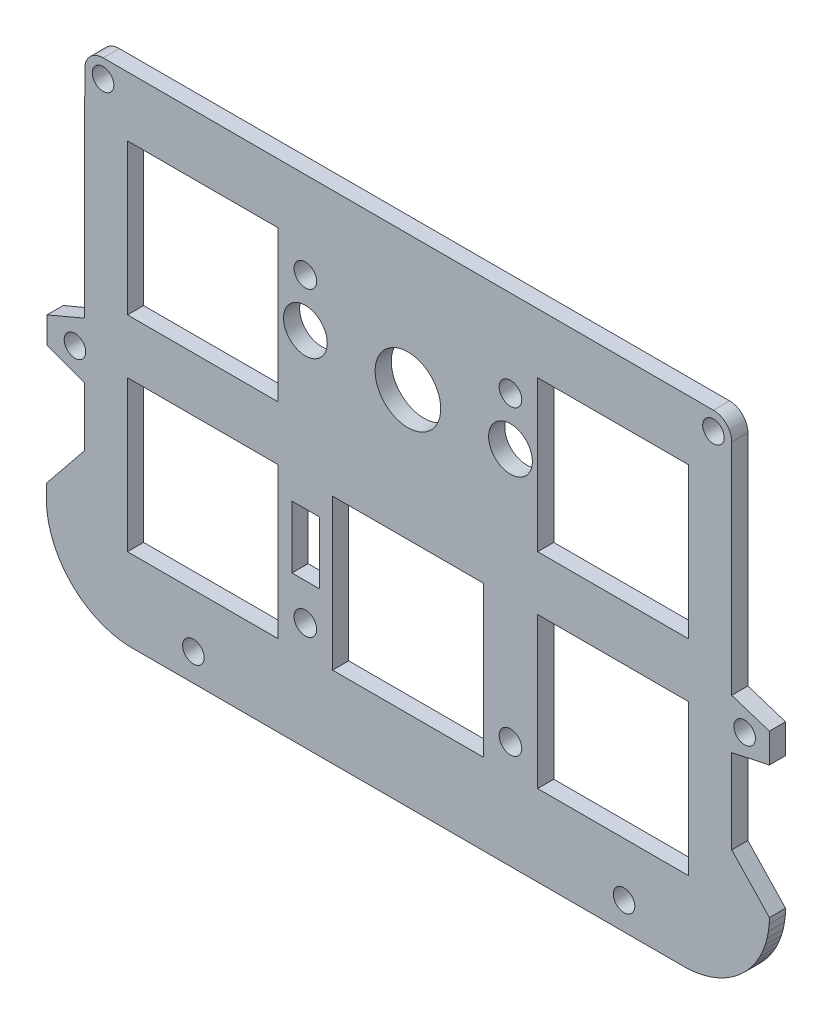
from build123d import *

# Parameters (mm, degrees)
MODEL_R         = 1
MODEL_R_2       = 1.05
MODEL_W         = 13.99947
MODEL_H         = 13.99944
MODEL_W_2       = 2.54
MODEL_H_2       = 5.78308735
MODEL_W_3       = 13.9994
MODEL_W_4       = 13.9993
MODEL_H_3       = 13.9993
MODEL_R_3       = 2.032
MODEL_R_4       = 3.048
EXTRUDE_1_DEPTH = 1.5


with BuildPart() as part:
    # Model → 凸台-拉伸1 (new body)
    with BuildSketch(Plane.XY):
        with BuildLine():
            Line((57.046434605, 41.37894176), (0.354810268, 41.37894176))
            ThreePointArc((0.354810268, 41.37894176), (-0.846923686, 40.881370762), (-1.345189448, 39.679924707))
            Line((-1.345189448, 39.679924707), (-1.353515518, 25.280051374))
            Line((-1.353515518, 25.280051374), (-1.356811329, 19.579970423))
            Line((-1.356811329, 19.579970423), (-4.853485523, 18.100805857))
            Line((-4.853485523, 18.100805857), (-4.853710523, 15.920120221))
            Line((-4.853710523, 15.920120221), (-4.853736766, 15.66577888))
            Line((-4.853736766, 15.66577888), (-1.359820188, 14.394107598))
            Line((-1.359820188, 14.394107598), (-1.362991715, 8.917997305))
            Line((-1.362991715, 8.917997305), (-4.9049154, 4.538497879))
            Line((-4.9049154, 4.538497879), (-4.9049154, 3.15597541))
            Line((-4.9049154, 3.15597541), (-4.883883595, 2.639206616))
            Line((-4.883883595, 2.639206616), (-4.813264805, 2.011073476))
            Line((-4.813264805, 2.011073476), (-4.687062167, 1.387481119))
            Line((-4.687062167, 1.387481119), (-4.516803943, 0.776764684))
            Line((-4.516803943, 0.776764684), (-4.295659415, 0.187060206))
            Line((-4.295659415, 0.187060206), (-4.03681533, -0.378036856))
            Line((-4.03681533, -0.378036856), (-3.730362364, -0.921623746))
            Line((-3.730362364, -0.921623746), (-3.390574278, -1.434889052))
            Line((-3.390574278, -1.434889052), (-2.992281832, -1.942165148))
            Line((-2.992281832, -1.942165148), (-2.558331876, -2.409802006))
            Line((-2.558331876, -2.409802006), (-2.102251702, -2.829663369))
            Line((-2.102251702, -2.829663369), (-1.614610519, -3.215411153))
            Line((-1.614610519, -3.215411153), (-1.088890304, -3.567123565))
            Line((-1.088890304, -3.567123565), (-0.532800957, -3.878547051))
            Line((-0.532800957, -3.878547051), (0.038326794, -4.140153507))
            Line((0.038326794, -4.140153507), (0.615600502, -4.353028424))
            Line((0.615600502, -4.353028424), (1.223529929, -4.526191258))
            Line((1.223529929, -4.526191258), (1.847223482, -4.64943937))
            Line((1.847223482, -4.64943937), (2.464503115, -4.722060038))
            Line((2.464503115, -4.722060038), (2.992774524, -4.743685))
            Line((2.992774524, -4.743685), (54.34686609, -4.743685))
            Line((54.34686609, -4.743685), (54.87843401, -4.722059086))
            Line((54.87843401, -4.722059086), (55.492240411, -4.649391053))
            Line((55.492240411, -4.649391053), (56.11599848, -4.526806688))
            Line((56.11599848, -4.526806688), (56.726168878, -4.352867841))
            Line((56.726168878, -4.352867841), (57.302144081, -4.140491025))
            Line((57.302144081, -4.140491025), (57.880206411, -3.875955859))
            Line((57.880206411, -3.875955859), (58.434482529, -3.563431063))
            Line((58.434482529, -3.563431063), (58.947571314, -3.220379587))
            Line((58.947571314, -3.220379587), (59.445938304, -2.8287768))
            Line((59.445938304, -2.8287768), (59.905767444, -2.401934126))
            Line((59.905767444, -2.401934126), (60.332973054, -1.941418241))
            Line((60.332973054, -1.941418241), (60.721224007, -1.446690794))
            Line((60.721224007, -1.446690794), (61.064717919, -0.934798534))
            Line((61.064717919, -0.934798534), (61.379380282, -0.376374826))
            Line((61.379380282, -0.376374826), (61.644240363, 0.202684675))
            Line((61.644240363, 0.202684675), (61.855333273, 0.776565869))
            Line((61.855333273, 0.776565869), (62.029241049, 1.384922025))
            Line((62.029241049, 1.384922025), (62.152356641, 2.011350393))
            Line((62.152356641, 2.011350393), (62.226202972, 2.636734827))
            Line((62.226202972, 2.636734827), (62.245297192, 3.166071528))
            Line((62.245297192, 3.166071528), (58.745412398, 6.86443549))
            Line((58.745412398, 6.86443549), (58.74568075, 14.685402523))
            Line((58.74568075, 14.685402523), (62.245579127, 15.434705638))
            Line((62.245579127, 15.434705638), (62.245861062, 18.167199282))
            Line((62.245861062, 18.167199282), (58.745799684, 19.296928449))
            Line((58.745799684, 19.296928449), (58.745975132, 24.929084585))
            Line((58.745975132, 24.929084585), (58.746434604, 39.678888803))
            ThreePointArc((58.746434604, 39.678888803), (58.248534856, 40.881004565), (57.046434605, 41.37894176))
        make_face()
        with Locations((8.744501265, -2.189788582)):
            Circle(MODEL_R, mode=Mode.SUBTRACT)
        with Locations((19.14575, 5.311768186)):
            Circle(MODEL_R_2, mode=Mode.SUBTRACT)
        with Locations((9.620765, 9.78198)):
            Rectangle(MODEL_W, MODEL_H, mode=Mode.SUBTRACT)
        with Locations((-2.255498735, 16.910211418)):
            Circle(MODEL_R, mode=Mode.SUBTRACT)
        with Locations((19.167580955, 11.605191102)):
            Rectangle(MODEL_W_2, MODEL_H_2, mode=Mode.SUBTRACT)
        with Locations((38.19575, 5.272237591)):
            Circle(MODEL_R_2, mode=Mode.SUBTRACT)
        with Locations((48.744501265, -2.189788582)):
            Circle(MODEL_R, mode=Mode.SUBTRACT)
        with Locations((28.6707, 9.78198)):
            Rectangle(MODEL_W_3, MODEL_H, mode=Mode.SUBTRACT)
        with Locations((47.72075, 9.78198)):
            Rectangle(MODEL_W_4, MODEL_H, mode=Mode.SUBTRACT)
        with Locations((59.944501265, 16.910211418)):
            Circle(MODEL_R, mode=Mode.SUBTRACT)
        with Locations((9.620765, 28.83195)):
            Rectangle(MODEL_W, MODEL_H_3, mode=Mode.SUBTRACT)
        with Locations((19.1458, 28.832)):
            Circle(MODEL_R_3, mode=Mode.SUBTRACT)
        with Locations((0.354810268, 39.67894176)):
            Circle(MODEL_R, mode=Mode.SUBTRACT)
        with Locations((19.14575, 33.310608186)):
            Circle(MODEL_R_2, mode=Mode.SUBTRACT)
        with Locations((28.6708, 28.832)):
            Circle(MODEL_R_4, mode=Mode.SUBTRACT)
        with Locations((38.1958, 28.832)):
            Circle(MODEL_R_3, mode=Mode.SUBTRACT)
        with Locations((47.72075, 28.83195)):
            Rectangle(MODEL_W_4, MODEL_H_3, mode=Mode.SUBTRACT)
        with Locations((38.194579287, 33.311869349)):
            Circle(MODEL_R_2, mode=Mode.SUBTRACT)
        with Locations((57.046434605, 39.67894176)):
            Circle(MODEL_R, mode=Mode.SUBTRACT)
    extrude(amount=EXTRUDE_1_DEPTH)


solid = part.part
